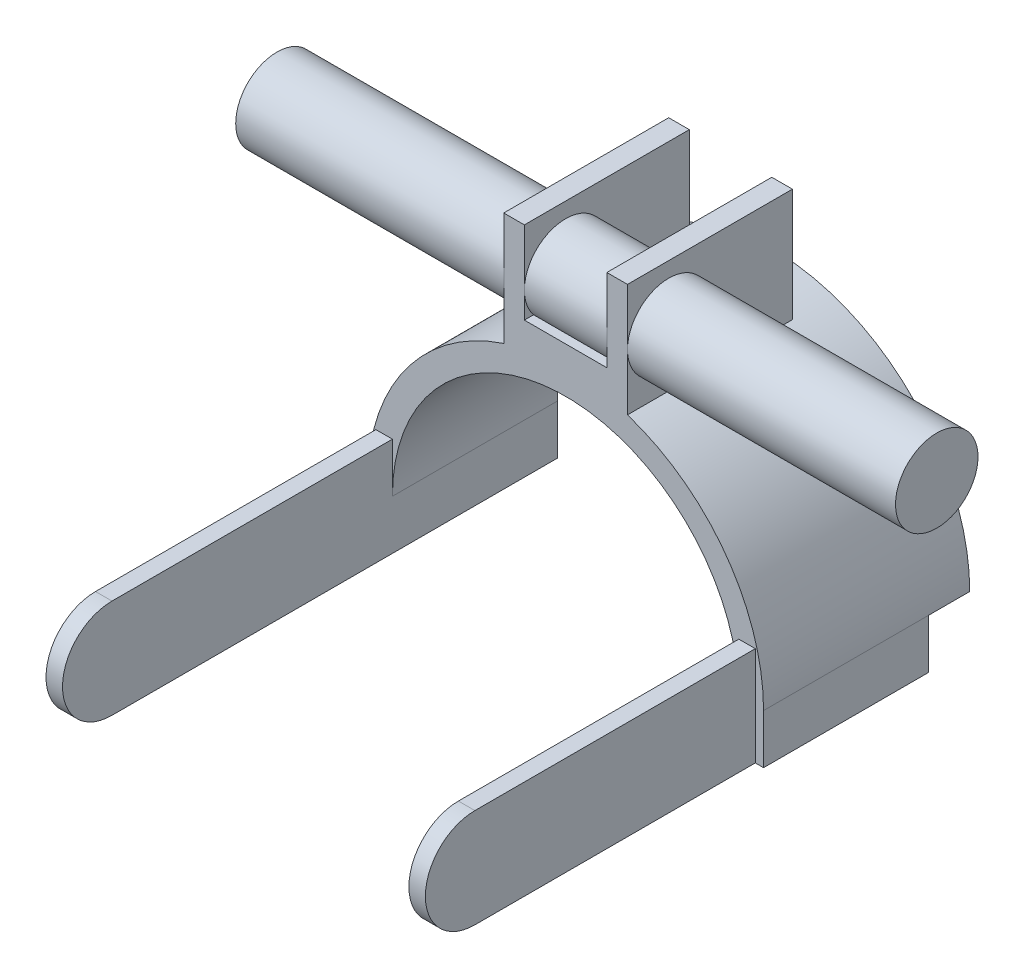
from build123d import *

# Parameters (mm, degrees)
EXTRUDE_1_DEPTH     = 10
EXTRUDE_2_DEPTH     = 40
EXTRUDE_4_DEPTH     = 40
SKETCH_7_W          = 4
SKETCH_7_H          = 24
EXTRUDE_5_DEPTH     = 120
CUT_EXTRUDE_3_DEPTH = 95
SKETCH_10_R         = 10
EXTRUDE_6_DEPTH     = 80


with BuildPart() as part:
    # 草图1 → 凸台-拉伸1 (new body)
    with BuildSketch(Plane.XY):
        with BuildLine():
            Line((-48, 0), (-46, 0))
            ThreePointArc((-46, 0), (0, 46), (46, 0))
            Line((46, 0), (48, 0))
            ThreePointArc((48, 0), (0, 48), (-48, 0))
        make_face()
    extrude(amount=EXTRUDE_1_DEPTH)

    # 草图2 → 凸台-拉伸2 (add)
    with BuildSketch(Plane.XY.offset(10)):
        with BuildLine():
            Line((-48, 0), (-48, -12))
            Line((-48, -12), (-46, -12))
            Line((-46, -12), (-46, 0))
            ThreePointArc((-46, 0), (0, 46), (46, 0))
            Line((46, 0), (46, -12))
            Line((46, -12), (48, -12))
            Line((48, -12), (48, 0))
            ThreePointArc((48, 0), (38.88444419, 28.142494559), (15, 45.596052461))
            Line((15, 45.596052461), (15, 73))
            Line((15, 73), (10, 73))
            Line((10, 73), (10, 53))
            Line((10, 53), (-10, 53))
            Line((-10, 53), (-10, 73))
            Line((-10, 73), (-15, 73))
            Line((-15, 73), (-15, 45.596052461))
            ThreePointArc((-15, 45.596052461), (-38.88444419, 28.142494559), (-48, 0))
        make_face()
    extrude(amount=EXTRUDE_2_DEPTH)

    # 草图6 → 凸台-拉伸4 (add)
    with BuildSketch(Plane(origin=(0, 0, 10), x_dir=(-1, 0, 0), z_dir=(0, 0, -1))):
        with BuildLine():
            Line((-46, 0), (-42.166380906, 0))
            Line((-42.166380906, 0), (-42, 0))
            ThreePointArc((-42, 0), (0, 42), (42, 0))
            Line((42, 0), (46, 0))
            ThreePointArc((46, 0), (0, 46), (-46, 0))
        make_face()
    extrude(amount=-EXTRUDE_4_DEPTH)

    # 草图7 → 凸台-拉伸5 (add)
    with BuildSketch(Plane(origin=(0, 0, 10), x_dir=(-1, 0, 0), z_dir=(0, 0, -1))):
        with Locations((-44, 0)):
            Rectangle(SKETCH_7_W, SKETCH_7_H)
        with Locations((44, 0)):
            Rectangle(SKETCH_7_W, SKETCH_7_H)
    extrude(amount=-EXTRUDE_5_DEPTH)

    # 草图8 → 切除-拉伸3 (cut, through all)
    with BuildSketch(Plane.ZY.offset(46)):
        with BuildLine():
            Line((118, 12), (136, 12))
            Line((136, 12), (136, -12))
            Line((136, -12), (118, -12))
            ThreePointArc((118, -12), (130, 0), (118, 12))
        make_face()
    extrude(amount=-CUT_EXTRUDE_3_DEPTH, mode=Mode.SUBTRACT)

    # 草图10 → 凸台-拉伸6 (add, symmetric)
    with BuildSketch(Plane(origin=(0, 0, 0), x_dir=(0, 0, -1), z_dir=(1, 0, 0))):
        with Locations((-40, 59.29802623)):
            Circle(SKETCH_10_R)
    extrude(amount=EXTRUDE_6_DEPTH, both=True)


solid = part.part
